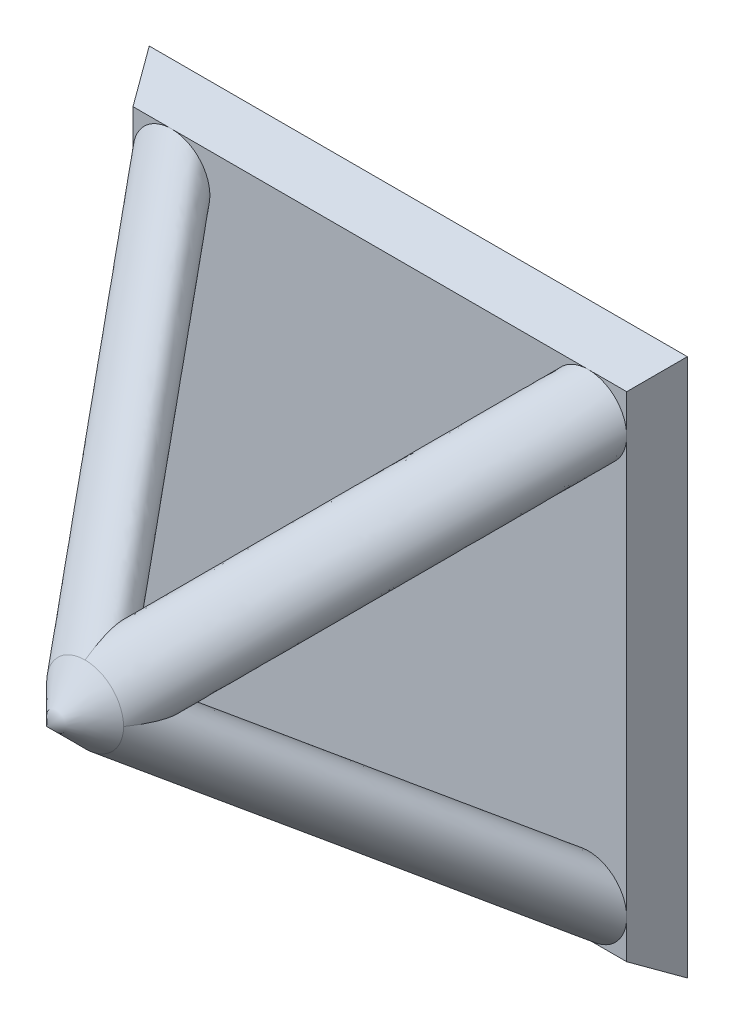
from build123d import *

# Parameters (mm, degrees)
SKETCH1_W           = 14
SKETCH1_H           = 14
BOSS_EXTRUDE1_DEPTH = 1
BOSS_EXTRUDE1_TAPER = 30
SKETCH2_R           = 1
CIRPATTERN1_COUNT   = 4
SKETCH4_R           = 1
BOSS_EXTRUDE2_DEPTH = 10
BOSS_EXTRUDE2_TAPER = 45


with BuildPart() as part:
    # Sketch1 → Boss-Extrude1 (new body)
    with BuildSketch(Plane.XY):
        Rectangle(SKETCH1_W, SKETCH1_H)
    extrude(amount=BOSS_EXTRUDE1_DEPTH, taper=BOSS_EXTRUDE1_TAPER)

    # Sweep1: sweep along a path in Sketch3
    with BuildLine(Plane(origin=(0, 0, 0), x_dir=(0, 0, -1), z_dir=(0.707106781, -0.707106781, 0))) as sweep1_path:
        Line((-1, 7.668784793), (-8.668784793, 0))
    # Sketch2 → Sweep1 (sweep)
    with BuildSketch(Plane.XY.offset(1)):
        with Locations((5.422649731, 5.422649731)):
            Circle(SKETCH2_R)
    sweep1 = sweep(path=sweep1_path.line)

    # CirPattern1: Sweep1 ×4 about axis
    cirpattern1_axis = Axis((0, 0, -4.23184126), (0, 0, 1))
    for i in range(1, CIRPATTERN1_COUNT):
        add(sweep1.rotate(cirpattern1_axis, i * 360 / CIRPATTERN1_COUNT))

    # Sketch4 → Boss-Extrude2 (add)
    with BuildSketch(Plane.XY.offset(8.668784793)):
        Circle(SKETCH4_R)
    extrude(amount=BOSS_EXTRUDE2_DEPTH, taper=BOSS_EXTRUDE2_TAPER)


solid = part.part
